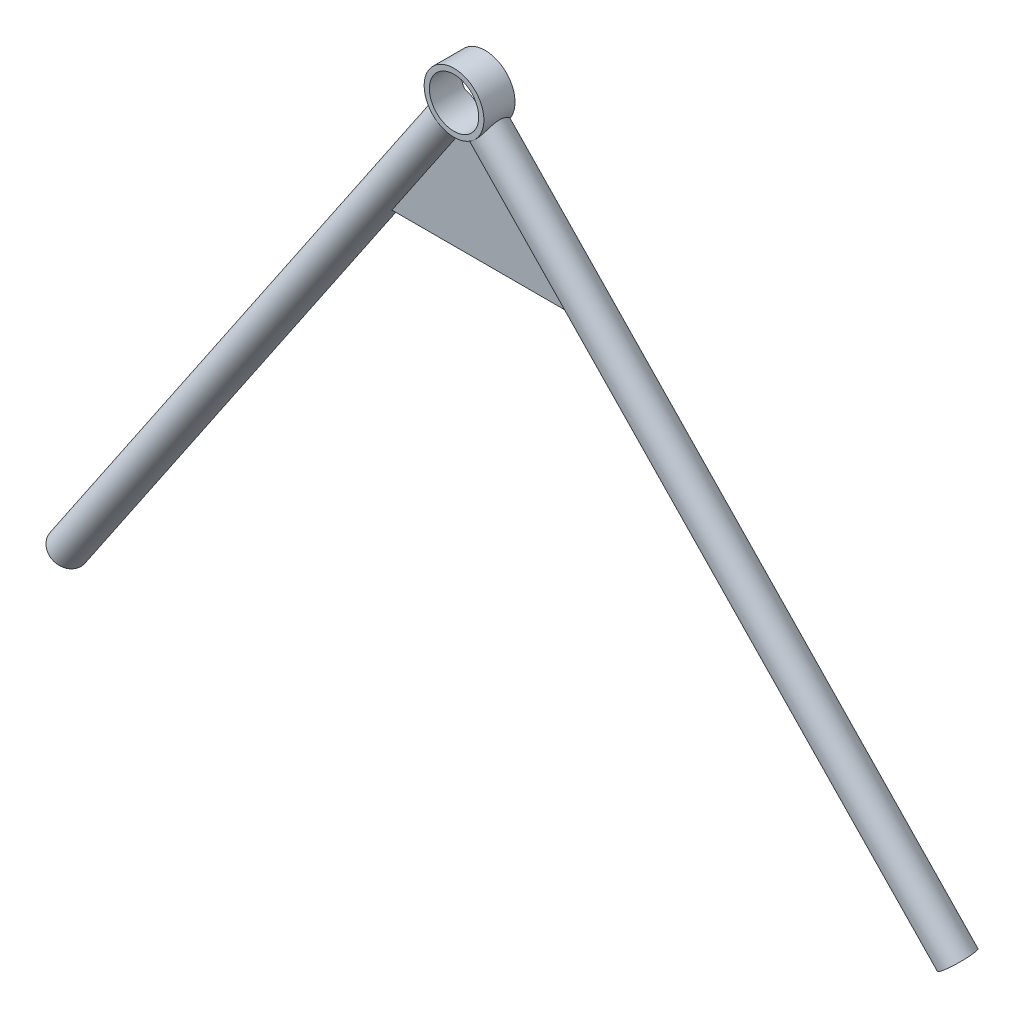
from build123d import *

# Parameters (mm, degrees)
SKETCH1_R               = 11.525
SKETCH1_R_2             = 9.525
BOSS_EXTRUDE1_DEPTH     = 6
SWEEP_THIN1_PROFILE_R   = 6.35
SWEEP_THIN1_PROFILE_R_2 = 5.35
SWEEP_THIN2_PROFILE_R   = 6.35
SWEEP_THIN2_PROFILE_R_2 = 5.35
BOSS_EXTRUDE2_DEPTH     = 2.5
CUT_EXTRUDE1_DEPTH      = 1075.028879602
CUT_EXTRUDE1_DEPTH_BACK = 1075.028879602
SKETCH1_4_R             = 9.525


with BuildPart() as part:
    # Sketch1 → Boss-Extrude1 (new, symmetric)
    with BuildSketch(Plane.XY.offset(205)):
        with Locations((738.34, 550.67)):
            Circle(SKETCH1_R)
        with Locations((738.34, 550.67)):
            Circle(SKETCH1_R_2, mode=Mode.SUBTRACT)
    extrude(amount=BOSS_EXTRUDE1_DEPTH, both=True)

    # Sweep-Thin1: sweep along a curve in space
    with BuildLine() as sweep_thin1_path:
        Line((738.34, 550.67, 205), (563.580835736, 301.820558935, 185.271096944))
    # Sweep-Thin1 profile (on start of the path) → Sweep-Thin1 (sweep)
    with BuildSketch(Plane(origin=(738.34, 550.67, 205), x_dir=(-0.8183587540369713, 0.5747077080491056, 0), z_dir=(-0.5735019266529007, -0.8166417738273465, -0.06474375155593219))):
        Circle(SWEEP_THIN1_PROFILE_R)
        Circle(SWEEP_THIN1_PROFILE_R_2, mode=Mode.SUBTRACT)
    sweep(path=sweep_thin1_path.line)

    # Sweep-Thin2: sweep along a curve in space
    with BuildLine() as sweep_thin2_path:
        Line((738.34, 550.67, 205), (909.8215428, 338.616273311, 188.188084039))
    # Sweep-Thin2 profile (on start of the path) → Sweep-Thin2 (sweep)
    with BuildSketch(Plane(origin=(738.34, 550.67, 205), x_dir=(-0.7775693400011727, -0.6287972021964958, 0), z_dir=(0.6276057797767632, -0.776096029462675, -0.06152997840948674))):
        Circle(SWEEP_THIN2_PROFILE_R)
        Circle(SWEEP_THIN2_PROFILE_R_2, mode=Mode.SUBTRACT)
    sweep(path=sweep_thin2_path.line)

    # Sketch2 → Boss-Extrude2 (add, symmetric)
    with BuildSketch(Plane(origin=(9.7477e-05, -12.711508297, 160.335052124), x_dir=(0.9999999999998164, 4.970716938152062e-08, -6.040203577873295e-07), z_dir=(6.060594888336047e-07, -0.0790329165021219, 0.9968720068839337))):
        Polygon((783.240874673, 509.450577665), (738.339903548, 565.149254574), (699.346819534, 509.450577665), align=None)
    extrude(amount=BOSS_EXTRUDE2_DEPTH, both=True)

    # Sketch1_4 → Cut-Extrude1 (cut, two sides: drawn at the far end of the back side and taken through both)
    with BuildSketch(Plane.XY.offset(205).offset(-CUT_EXTRUDE1_DEPTH_BACK)):
        with Locations((738.34, 550.67)):
            Circle(SKETCH1_4_R)
    extrude(amount=CUT_EXTRUDE1_DEPTH + CUT_EXTRUDE1_DEPTH_BACK, mode=Mode.SUBTRACT)


solid = part.part
